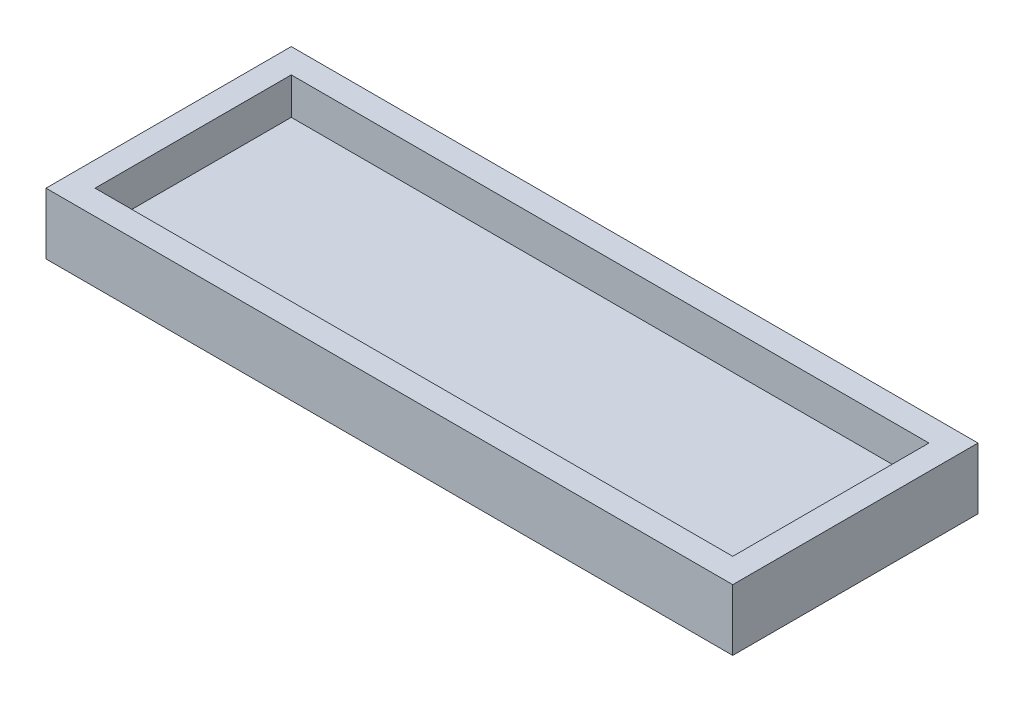
from build123d import *

# Parameters (mm, degrees)
SKETCH_1_W           = 26
SKETCH_1_H           = 8
EXTRUDE_1_DEPTH      = 1
SKETCH_2_W           = 28
SKETCH_2_H           = 10
SKETCH_2_W_2         = 26
SKETCH_2_H_2         = 8
EXTRUDE_2_DEPTH      = 1.5
EXTRUDE_2_DEPTH_BACK = 1


with BuildPart() as part:
    # 草图1 → 凸台-拉伸1 (new body)
    with BuildSketch(Plane(origin=(0, 0, 0), x_dir=(1, 0, 0), z_dir=(0, 1, 0))):
        Rectangle(SKETCH_1_W, SKETCH_1_H)
    extrude(amount=EXTRUDE_1_DEPTH)

    # 草图2 → 凸台-拉伸2 (add, two sides)
    with BuildSketch(Plane(origin=(0, 1, 0), x_dir=(1, 0, 0), z_dir=(0, 1, 0))) as extrude_2_sk:
        Rectangle(SKETCH_2_W, SKETCH_2_H)
        Rectangle(SKETCH_2_W_2, SKETCH_2_H_2, mode=Mode.SUBTRACT)
    extrude(amount=EXTRUDE_2_DEPTH)
    extrude(extrude_2_sk.sketch, amount=-EXTRUDE_2_DEPTH_BACK)


solid = part.part
